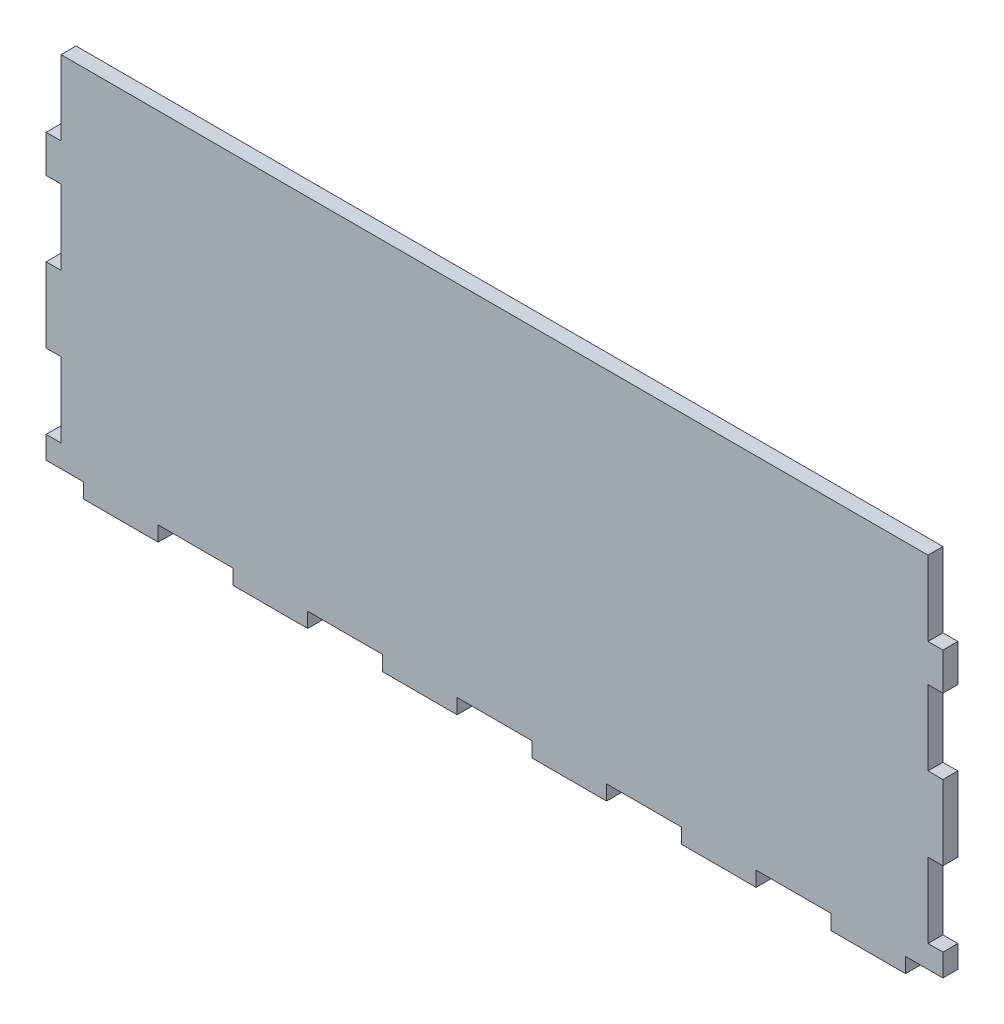
from build123d import *

# Parameters (mm, degrees)
BOSS_EXTRUDE1_DEPTH = 2.54


with BuildPart() as part:
    # Sketch1 → Boss-Extrude1 (new body, symmetric)
    with BuildSketch(Plane.XY):
        Polygon((147.32, -25.4), (147.32, 0), (-147.32, 0), (-147.32, -25.4), (-152.4, -25.4), (-152.4, -38.1), (-147.32, -38.1), (-147.32, -63.5), (-152.4, -63.5), (-152.4, -88.9), (-147.32, -88.9), (-147.32, -114.3), (-152.4, -114.3), (-152.4, -121.92), (-139.7, -121.92), (-139.7, -127), (-114.3, -127), (-114.3, -121.92), (-88.9, -121.92), (-88.9, -127), (-63.5, -127), (-63.5, -121.92), (-38.1, -121.92), (-38.1, -127), (-12.7, -127), (-12.7, -121.92), (12.7, -121.92), (12.7, -127), (38.1, -127), (38.1, -121.92), (63.5, -121.92), (63.5, -127), (88.9, -127), (88.9, -121.92), (114.3, -121.92), (114.3, -127), (139.7, -127), (139.7, -121.92), (152.4, -121.92), (152.4, -114.3), (147.32, -114.3), (147.32, -88.9), (152.4, -88.9), (152.4, -63.5), (147.32, -63.5), (147.32, -38.1), (152.4, -38.1), (152.4, -25.4), align=None)
    extrude(amount=BOSS_EXTRUDE1_DEPTH, both=True)


solid = part.part
